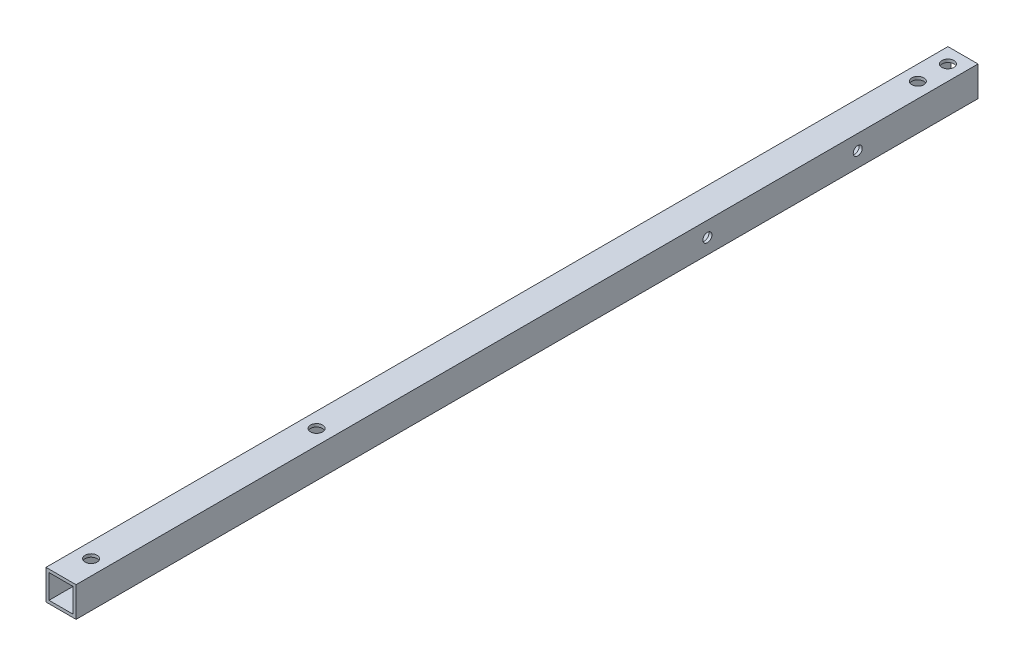
from build123d import *

# Parameters (mm, degrees)
SKETCH_1_W          = 10
SKETCH_1_H          = 10
SKETCH_1_W_2        = 8
SKETCH_1_H_2        = 8
EXTRUDE_1_DEPTH     = 300
SKETCH_2_R          = 2
CUT_EXTRUDE_1_DEPTH = 11
SKETCH_3_R          = 1.5
CUT_EXTRUDE_2_DEPTH = 11


with BuildPart() as part:
    # Эскиз1 → Бобышка-Вытянуть1 (new body)
    with BuildSketch(Plane.XY):
        with Locations((5, -5)):
            Rectangle(SKETCH_1_W, SKETCH_1_H)
        with Locations((5, -5)):
            Rectangle(SKETCH_1_W_2, SKETCH_1_H_2, mode=Mode.SUBTRACT)
    extrude(amount=EXTRUDE_1_DEPTH)

    # Эскиз2 → Вырез-Вытянуть1 (cut, through all)
    with BuildSketch(Plane(origin=(0, 0, 0), x_dir=(1, 0, 0), z_dir=(0, 1, 0))):
        with Locations((5, -5)):
            Circle(SKETCH_2_R)
        with Locations((5, -15)):
            Circle(SKETCH_2_R)
        with Locations((5, -290)):
            Circle(SKETCH_2_R)
        with Locations((5, -215)):
            Circle(SKETCH_2_R)
    extrude(amount=-CUT_EXTRUDE_1_DEPTH, mode=Mode.SUBTRACT)

    # Эскиз3 → Вырез-Вытянуть2 (cut, through all)
    with BuildSketch(Plane(origin=(10, 0, 0), x_dir=(0, 0, -1), z_dir=(1, 0, 0))):
        with Locations((-40, -5)):
            Circle(SKETCH_3_R)
        with Locations((-90, -5)):
            Circle(SKETCH_3_R)
    extrude(amount=-CUT_EXTRUDE_2_DEPTH, mode=Mode.SUBTRACT)


solid = part.part
